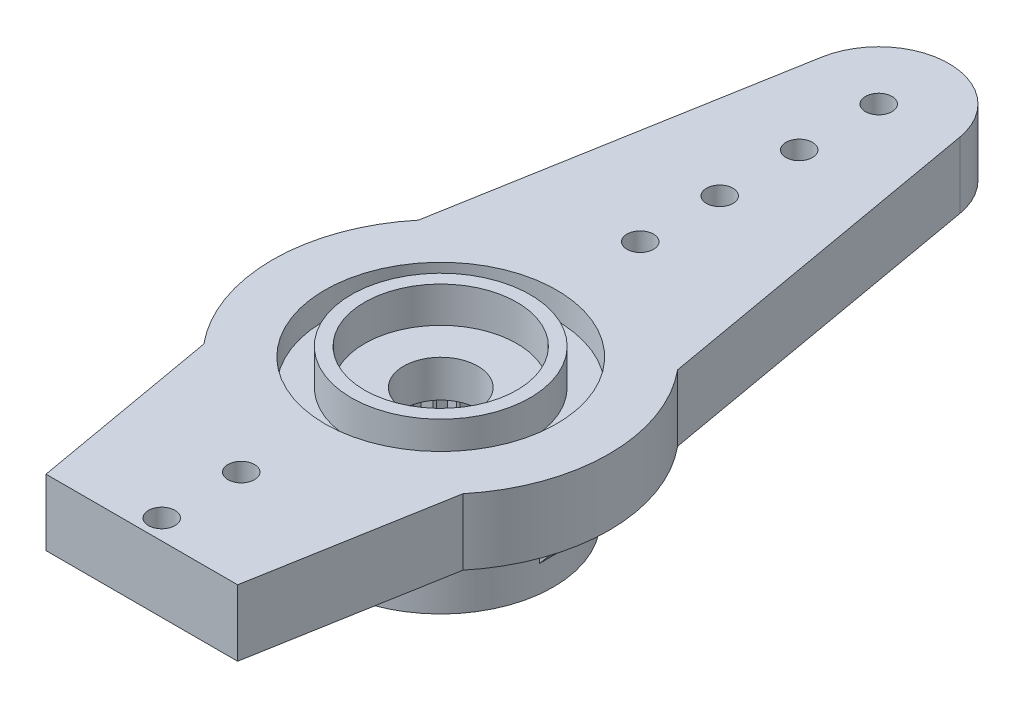
from build123d import *

# Parameters (mm, degrees)
SKETCH1_R               = 6.35
BOSS_EXTRUDE1_DEPTH     = 5.4
HORN_DEPTH              = 2.5
SKETCH4_R               = 1.4
CUT_EXTRUDE1_DEPTH      = 6.4
SKETCH5_R               = 0.5
CUT_EXTRUDE2_DEPTH      = 6.4
LPATTERN1_COUNT         = 4
LPATTERN1_PITCH         = 3
MIRROR1_COPY_1_SKETCH_R = 0.5
MIRROR1_COPY_1_DEPTH    = 6.4
MIRROR1_COPY_2_SKETCH_R = 0.5
MIRROR1_COPY_2_DEPTH    = 6.4
MIRROR1_COPY_3_SKETCH_R = 0.5
MIRROR1_COPY_3_DEPTH    = 6.4
CUT_EXTRUDE4_DEPTH      = 3
CIRPATTERN2_COUNT       = 26
SKETCH9_R               = 2.6
CUT_EXTRUDE5_DEPTH      = 3
SKETCH10_R              = 6.35
SKETCH10_R_2            = 4.25
CUT_EXTRUDE6_DEPTH      = 2.9
BOSS_EXTRUDE5_DEPTH     = 0.5
CIRPATTERN3_COUNT       = 4
SKETCH12_R              = 4.375
CUT_EXTRUDE7_DEPTH      = 1
SKETCH13_R              = 3.375
SKETCH13_R_2            = 2.875
BOSS_EXTRUDE6_DEPTH     = 1
SKETCH14_R              = 3.375
SKETCH14_R_2            = 2.875
BOSS_EXTRUDE7_DEPTH     = 0.35
CUT_EXTRUDE8_DEPTH      = 6.4


with BuildPart() as part:
    # Sketch1 → Boss-Extrude1 (new body)
    with BuildSketch(Plane(origin=(0, 0, 0), x_dir=(1, 0, 0), z_dir=(0, 1, 0))):
        Circle(SKETCH1_R)
    extrude(amount=BOSS_EXTRUDE1_DEPTH)

    # Sketch2 → horn (add)
    with BuildSketch(Plane(origin=(0, 5.4, 0), x_dir=(1, 0, 0), z_dir=(0, 1, 0))):
        with BuildLine():
            Line((-2.609740545, 16.990167671), (-4.891612682, 4.049027706))
            ThreePointArc((-4.891612682, 4.049027706), (0, 6.35), (4.891612682, 4.049027706))
            Line((4.891612682, 4.049027706), (2.609740545, 16.990167671))
            ThreePointArc((2.609740545, 16.990167671), (0, 19.18), (-2.609740545, 16.990167671))
        make_face()
    horn = extrude(amount=-HORN_DEPTH)

    # Sketch4 → Cut-Extrude1 (cut, through all)
    with BuildSketch(Plane(origin=(0, 5.4, 0), x_dir=(-1, 0, 0), z_dir=(0, -1, 0))):
        Circle(SKETCH4_R)
    extrude(amount=CUT_EXTRUDE1_DEPTH, mode=Mode.SUBTRACT)

    # Sketch5 → Cut-Extrude2 (cut, through all)
    with BuildSketch(Plane(origin=(0, 0, 0), x_dir=(-1, 0, 0), z_dir=(0, -1, 0))):
        with Locations((0, 16.53)):
            Circle(SKETCH5_R)
    cut_extrude2 = extrude(amount=-CUT_EXTRUDE2_DEPTH, mode=Mode.SUBTRACT)

    # LPattern1: Cut-Extrude2 ×4
    with Locations(*[(0, 0, i * LPATTERN1_PITCH) for i in range(1, LPATTERN1_COUNT)]):
        add(cut_extrude2, mode=Mode.SUBTRACT)

    # Mirror1: horn, Cut-Extrude2 across plane
    add(horn.mirror(Plane.XY))
    add(cut_extrude2.mirror(Plane.XY), mode=Mode.SUBTRACT)

    # Mirror1 copy 1 sketch → Mirror1 copy 1 (cut, through all)
    with BuildSketch(Plane(origin=(0, 0, -3), x_dir=(-1, 0, 0), z_dir=(0, -1, 0))):
        with Locations((0, -16.53)):
            Circle(MIRROR1_COPY_1_SKETCH_R)
    extrude(amount=-MIRROR1_COPY_1_DEPTH, mode=Mode.SUBTRACT)

    # Mirror1 copy 2 sketch → Mirror1 copy 2 (cut, through all)
    with BuildSketch(Plane(origin=(0, 0, -6), x_dir=(-1, 0, 0), z_dir=(0, -1, 0))):
        with Locations((0, -16.53)):
            Circle(MIRROR1_COPY_2_SKETCH_R)
    extrude(amount=-MIRROR1_COPY_2_DEPTH, mode=Mode.SUBTRACT)

    # Mirror1 copy 3 sketch → Mirror1 copy 3 (cut, through all)
    with BuildSketch(Plane(origin=(0, 0, -9), x_dir=(-1, 0, 0), z_dir=(0, -1, 0))):
        with Locations((0, -16.53)):
            Circle(MIRROR1_COPY_3_SKETCH_R)
    extrude(amount=-MIRROR1_COPY_3_DEPTH, mode=Mode.SUBTRACT)

    # Sketch8 → Cut-Extrude4 (cut)
    with BuildSketch(Plane(origin=(0, 0, 0), x_dir=(-1, 0, 0), z_dir=(0, -1, 0))):
        with BuildLine():
            Line((0, -2.9), (0.262912611, -2.586672952))
            ThreePointArc((0.262912611, -2.586672952), (0, -2.6), (-0.262912611, -2.586672952))
            Line((-0.262912611, -2.586672952), (0, -2.9))
        make_face()
    cut_extrude4 = extrude(amount=-CUT_EXTRUDE4_DEPTH, mode=Mode.SUBTRACT)

    # CirPattern2: Cut-Extrude4 ×26 about axis
    cirpattern2_axis = Axis((0, 0, 0), (0, 1, 0))
    for i in range(1, CIRPATTERN2_COUNT):
        add(cut_extrude4.rotate(cirpattern2_axis, i * 360 / CIRPATTERN2_COUNT), mode=Mode.SUBTRACT)

    # Sketch9 → Cut-Extrude5 (cut)
    with BuildSketch(Plane(origin=(0, 0, 0), x_dir=(-1, 0, 0), z_dir=(0, -1, 0))):
        Circle(SKETCH9_R)
    extrude(amount=-CUT_EXTRUDE5_DEPTH, mode=Mode.SUBTRACT)

    # Sketch10 → Cut-Extrude6 (cut)
    with BuildSketch(Plane(origin=(0, 0, 0), x_dir=(-1, 0, 0), z_dir=(0, -1, 0))):
        Circle(SKETCH10_R)
        Circle(SKETCH10_R_2, mode=Mode.SUBTRACT)
    extrude(amount=-CUT_EXTRUDE6_DEPTH, mode=Mode.SUBTRACT)

    # Sketch11 → Boss-Extrude5 (add, symmetric)
    with BuildSketch(Plane.XY):
        Polygon((4.21, 0.99), (5.812680296, 2.9), (4.21, 2.9), (4.16, 2.9), (4.16, 0.99), align=None)
    boss_extrude5 = extrude(amount=BOSS_EXTRUDE5_DEPTH, both=True)

    # CirPattern3: Boss-Extrude5 ×4 about axis
    cirpattern3_axis = Axis((0, 0, 0), (0, 1, 0))
    for i in range(1, CIRPATTERN3_COUNT):
        add(boss_extrude5.rotate(cirpattern3_axis, i * 360 / CIRPATTERN3_COUNT))

    # Sketch12 → Cut-Extrude7 (cut)
    with BuildSketch(Plane(origin=(0, 5.4, 0), x_dir=(1, 0, 0), z_dir=(0, 1, 0))):
        Circle(SKETCH12_R)
    extrude(amount=-CUT_EXTRUDE7_DEPTH, mode=Mode.SUBTRACT)

    # Sketch13 → Boss-Extrude6 (add)
    with BuildSketch(Plane(origin=(0, 4.4, 0), x_dir=(1, 0, 0), z_dir=(0, 1, 0))):
        Circle(SKETCH13_R)
        Circle(SKETCH13_R_2, mode=Mode.SUBTRACT)
    extrude(amount=BOSS_EXTRUDE6_DEPTH)

    # Sketch14 → Boss-Extrude7 (add)
    with BuildSketch(Plane(origin=(0, 5.4, 0), x_dir=(1, 0, 0), z_dir=(0, 1, 0))):
        Circle(SKETCH14_R)
        Circle(SKETCH14_R_2, mode=Mode.SUBTRACT)
    extrude(amount=BOSS_EXTRUDE7_DEPTH)

    # Sketch15 → Cut-Extrude8 (cut, through all)
    with BuildSketch(Plane(origin=(0, 5.4, 0), x_dir=(1, 0, 0), z_dir=(0, 1, 0))):
        Polygon((-3.616359732, -11.281346581), (3.616359732, -11.281346581), (9.32149419, -16.388605274), (4.660747095, -20.846711191), (-5.775273574, -20.846711191), (-10.680070262, -15.7189692), (-9.733647563, -14.813695314), align=None)
    extrude(amount=-CUT_EXTRUDE8_DEPTH, mode=Mode.SUBTRACT)


solid = part.part
